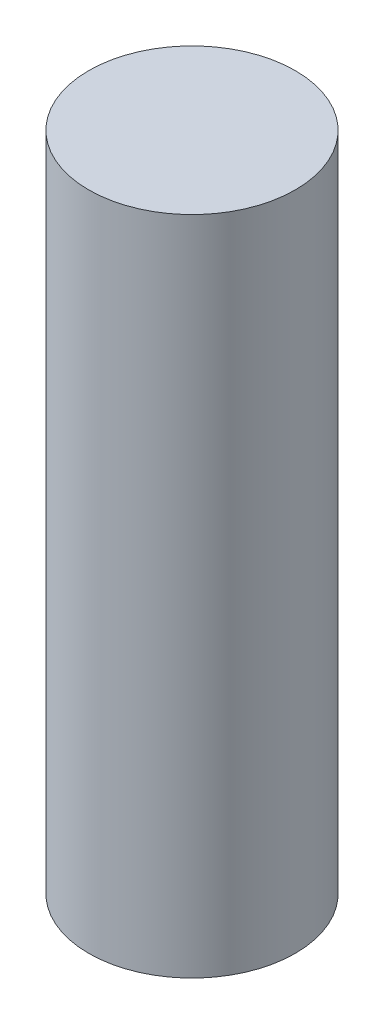
from build123d import *

# Parameters (mm, degrees)
SKETCH1_R           = 0.3125
BOSS_EXTRUDE1_DEPTH = 1


with BuildPart() as part:
    # Sketch1 → Boss-Extrude1 (new body, symmetric)
    with BuildSketch(Plane(origin=(0, 0, 0), x_dir=(1, 0, 0), z_dir=(0, 1, 0))):
        Circle(SKETCH1_R)
    extrude(amount=BOSS_EXTRUDE1_DEPTH, both=True)


solid = part.part
